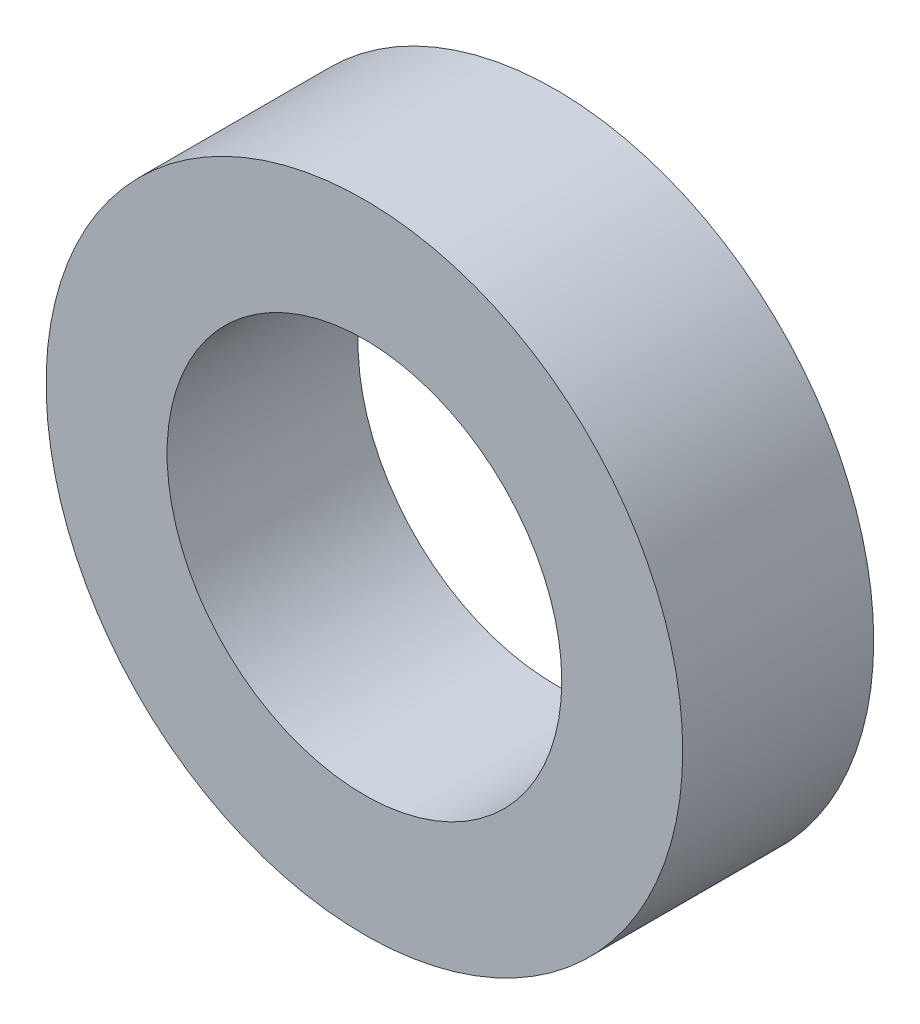
from build123d import *

# Parameters (mm, degrees)
SKETCH_1_R      = 5
SKETCH_1_R_2    = 3.1
EXTRUDE_1_DEPTH = 3


with BuildPart() as part:
    # ｽｹｯﾁ1 → ﾎﾞｽ - 押し出し1 (new body)
    with BuildSketch(Plane.XY):
        Circle(SKETCH_1_R)
        Circle(SKETCH_1_R_2, mode=Mode.SUBTRACT)
    extrude(amount=EXTRUDE_1_DEPTH)


solid = part.part
